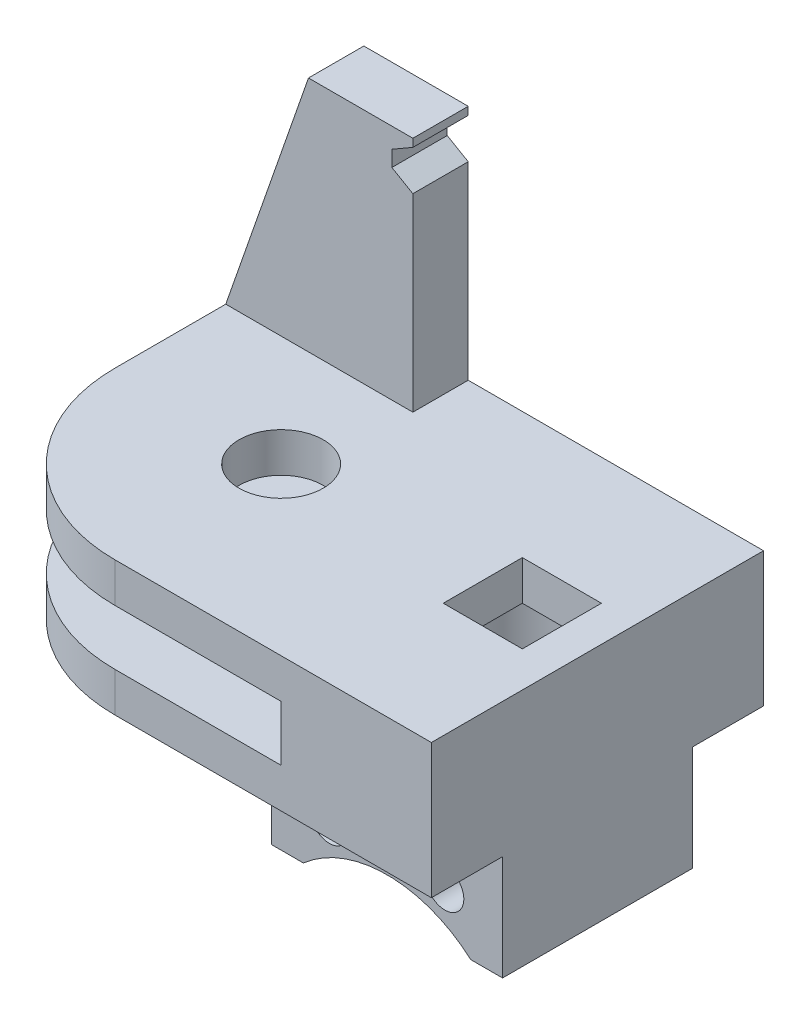
from build123d import *

# Parameters (mm, degrees)
SKETCH1_R            = 3.3782
BOSS_EXTRUDE1_DEPTH  = 3.175
BOSS_EXTRUDE2_DEPTH  = 4.445
SKETCH7_W            = 18.542
SKETCH7_H            = 15.24
BOSS_EXTRUDE4_DEPTH  = 8.43915
SKETCH8_R            = 1.524
CUT_EXTRUDE3_DEPTH   = 21.955
SKETCH9_R            = 10.16
CUT_EXTRUDE4_DEPTH   = 21.955
SKETCH22_W           = 6.35
SKETCH22_H           = 6.35
CUT_EXTRUDE6_DEPTH   = 9.525
SKETCH23_R           = 4.490128061
CUT_EXTRUDE7_DEPTH   = 6.35
BOSS_EXTRUDE10_DEPTH = 3.175
BOSS_EXTRUDE11_DEPTH = 3.175
SKETCH19_W           = 8.382
SKETCH19_H           = 4.445
BOSS_EXTRUDE12_DEPTH = 19.05
BOSS_EXTRUDE13_DEPTH = 4.445
CUT_EXTRUDE5_DEPTH   = 12.7


with BuildPart() as part:
    # Sketch1 → Boss-Extrude1 (new body)
    with BuildSketch(Plane(origin=(0, 0, 0), x_dir=(1, 0, 0), z_dir=(0, 1, 0))):
        with BuildLine():
            Line((0, -13.335), (25.4, -13.335))
            Line((25.4, -13.335), (25.4, 13.335))
            Line((25.4, 13.335), (0, 13.335))
            ThreePointArc((0, 13.335), (-13.335, 0), (0, -13.335))
        make_face()
        Circle(SKETCH1_R, mode=Mode.SUBTRACT)
    boss_extrude1 = extrude(amount=BOSS_EXTRUDE1_DEPTH)

    # Sketch2 → Boss-Extrude2 (add)
    with BuildSketch(Plane(origin=(0, 0, 0), x_dir=(-1, 0, 0), z_dir=(0, -1, 0))):
        Polygon((-25.4, 13.335), (-25.4, -13.335), (-13.335, -13.335), (-13.335, 0), (-13.335, 13.335), align=None)
    extrude(amount=BOSS_EXTRUDE2_DEPTH)

    # Mirror2: Boss-Extrude1 across plane
    add(boss_extrude1.mirror(Plane(origin=(0, -2.2225, 0), x_dir=(0, 0, 1), z_dir=(0, -1, 0))))

    # Sketch7 → Boss-Extrude4 (add)
    with BuildSketch(Plane(origin=(0, -7.62, 0), x_dir=(-1, 0, 0), z_dir=(0, -1, 0))):
        with Locations((-16.129, 0)):
            Rectangle(SKETCH7_W, SKETCH7_H)
    extrude(amount=BOSS_EXTRUDE4_DEPTH)

    # Sketch8 → Cut-Extrude3 (cut, through all)
    with BuildSketch(Plane(origin=(0, 0, -7.62), x_dir=(-1, 0, 0), z_dir=(0, 0, -1))):
        with Locations((-20.7645, -12.1285)):
            Circle(SKETCH8_R)
        with Locations((-11.4935, -12.1285)):
            Circle(SKETCH8_R)
    extrude(amount=-CUT_EXTRUDE3_DEPTH, mode=Mode.SUBTRACT)

    # Sketch9 → Cut-Extrude4 (cut, through all)
    with BuildSketch(Plane(origin=(0, 0, -7.62), x_dir=(-1, 0, 0), z_dir=(0, 0, -1))):
        with Locations((-16.129, -23.67915)):
            Circle(SKETCH9_R)
    extrude(amount=-CUT_EXTRUDE4_DEPTH, mode=Mode.SUBTRACT)

    # Sketch22 → Cut-Extrude6 (cut)
    with BuildSketch(Plane(origin=(0, 3.175, 0), x_dir=(1, 0, 0), z_dir=(0, 1, 0))):
        with Locations((19.3675, 0)):
            Rectangle(SKETCH22_W, SKETCH22_H)
    extrude(amount=-CUT_EXTRUDE6_DEPTH, mode=Mode.SUBTRACT)

    # Sketch23 → Cut-Extrude7 (cut)
    with BuildSketch(Plane(origin=(0, -6.35, 0), x_dir=(1, 0, 0), z_dir=(0, 1, 0))):
        with Locations((19.3675, 0)):
            Circle(SKETCH23_R)
    extrude(amount=CUT_EXTRUDE7_DEPTH, mode=Mode.SUBTRACT)

    # Sketch16 → Boss-Extrude10 (add)
    with BuildSketch(Plane(origin=(0, 3.175, 0), x_dir=(1, 0, 0), z_dir=(0, 1, 0))):
        Polygon((0, 13.335), (-13.335, 0), (-13.335, 13.335), align=None)
    extrude(amount=-BOSS_EXTRUDE10_DEPTH)

    # Sketch17 → Boss-Extrude11 (add)
    with BuildSketch(Plane.XZ.offset(7.62)):
        Polygon((-13.335, -13.335), (-13.335, 0), (0, -13.335), align=None)
    extrude(amount=-BOSS_EXTRUDE11_DEPTH)

    # Sketch19 → Boss-Extrude12 (add)
    with BuildSketch(Plane(origin=(0, 3.175, 0), x_dir=(1, 0, 0), z_dir=(0, 1, 0))):
        with Locations((-2.5019, 11.1125)):
            Rectangle(SKETCH19_W, SKETCH19_H)
    extrude(amount=BOSS_EXTRUDE12_DEPTH)

    # Sketch20 → Boss-Extrude13 (add)
    with BuildSketch(Plane.XY.offset(-8.89)):
        Polygon((-6.6929, 22.225), (-13.335, 3.175), (-6.6929, 3.175), align=None)
    extrude(amount=-BOSS_EXTRUDE13_DEPTH)

    # Sketch21 → Cut-Extrude5 (cut)
    with BuildSketch(Plane.XY.offset(-8.89)):
        Polygon((0, 20.61479766), (1.6891, 21.59), (1.6891, 18.369595321), (0, 19.34479766), align=None)
    extrude(amount=-CUT_EXTRUDE5_DEPTH, mode=Mode.SUBTRACT)


solid = part.part
